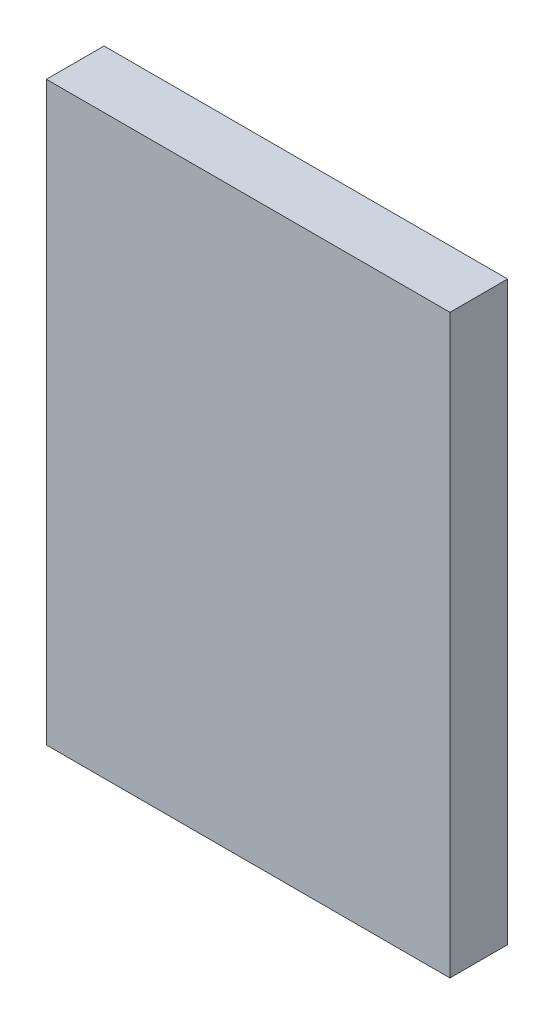
from build123d import *

# Parameters (mm, degrees)
SKETCH1_W           = 350
SKETCH1_H           = 500
BOSS_EXTRUDE1_DEPTH = 25


with BuildPart() as part:
    # Sketch1 → Boss-Extrude1 (new body, symmetric)
    with BuildSketch(Plane.XY):
        Rectangle(SKETCH1_W, SKETCH1_H)
    extrude(amount=BOSS_EXTRUDE1_DEPTH, both=True)


solid = part.part
